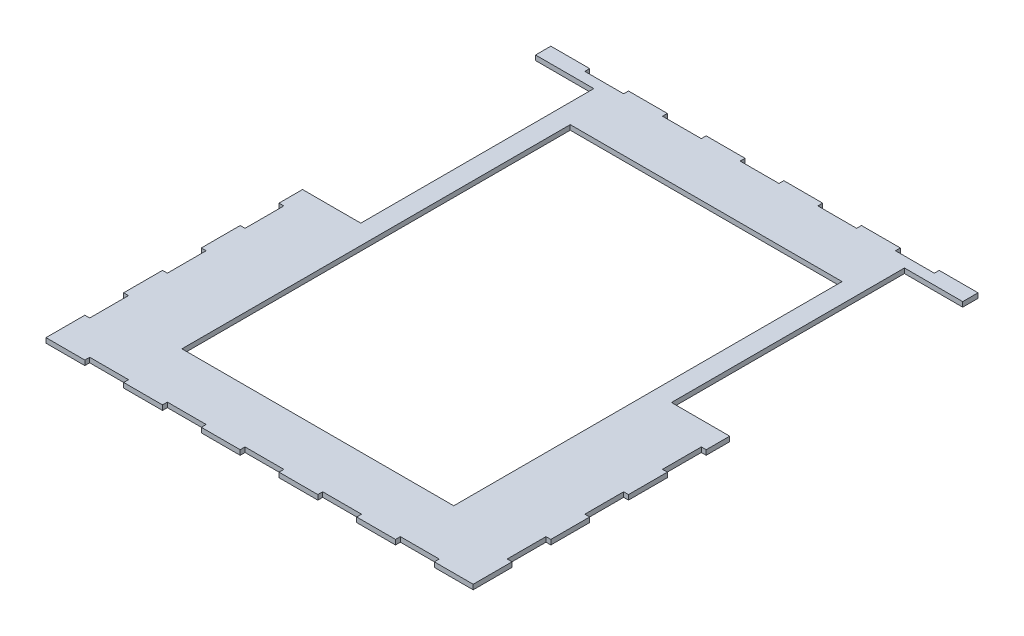
from build123d import *

# Parameters (mm, degrees)
BOSS_EXTRUDE1_DEPTH     = 3.175
SKETCH4_W               = 38.1
SKETCH4_H               = 152.4
CUT_EXTRUDE2_DEPTH      = 1
CUT_EXTRUDE2_DEPTH_BACK = 4.175
SKETCH2_W               = 177.8
SKETCH2_H               = 254
CUT_EXTRUDE1_DEPTH      = 1
CUT_EXTRUDE1_DEPTH_BACK = 4.175


with BuildPart() as part:
    # Sketch1 → Boss-Extrude1 (new body)
    with BuildSketch(Plane(origin=(0, 0, 0), x_dir=(1, 0, 0), z_dir=(0, 1, 0))):
        Polygon((-139.7, 0), (0, 0), (0, 161.925), (-12.7, 161.925), (-12.7, 165.1), (-38.1, 165.1), (-38.1, 161.925), (-63.5, 161.925), (-63.5, 165.1), (-88.9, 165.1), (-88.9, 161.925), (-114.3, 161.925), (-114.3, 165.1), (-139.7, 165.1), (-139.7, 139.7), (-136.525, 139.7), (-136.525, 114.3), (-139.7, 114.3), (-139.7, 88.9), (-136.525, 88.9), (-136.525, 63.5), (-139.7, 63.5), (-139.7, 38.1), (-136.525, 38.1), (-136.525, 12.7), (-139.7, 12.7), align=None)
    extrude(amount=BOSS_EXTRUDE1_DEPTH)

    # Mirror1: part across plane


with BuildPart() as part_1:
    add(part.part)
    add(part.part.mirror(Plane(origin=(-139.7, 3.175, 0), x_dir=(1, 0, 0), z_dir=(0, 0, -1))))

    # Sketch4 → Cut-Extrude2 (cut, two sides)
    with BuildSketch(Plane(origin=(0, 3.175, 0), x_dir=(1, 0, 0), z_dir=(0, 1, 0))) as cut_extrude2_sk:
        with Locations((-120.65, 78.9)):
            Rectangle(SKETCH4_W, SKETCH4_H)
    extrude(amount=CUT_EXTRUDE2_DEPTH, mode=Mode.SUBTRACT)
    extrude(cut_extrude2_sk.sketch, amount=-CUT_EXTRUDE2_DEPTH_BACK, mode=Mode.SUBTRACT)

    # Mirror2: part across plane


with BuildPart() as part_2:
    add(part_1.part)
    add(part_1.part.mirror(Plane(origin=(0, 3.175, 0), x_dir=(0, 0, 1), z_dir=(-1, 0, 0))))

    # Sketch2 → Cut-Extrude1 (cut, two sides)
    with BuildSketch(Plane(origin=(0, 3.175, 0), x_dir=(1, 0, 0), z_dir=(0, 1, 0))) as cut_extrude1_sk:
        Rectangle(SKETCH2_W, SKETCH2_H)
    extrude(amount=CUT_EXTRUDE1_DEPTH, mode=Mode.SUBTRACT)
    extrude(cut_extrude1_sk.sketch, amount=-CUT_EXTRUDE1_DEPTH_BACK, mode=Mode.SUBTRACT)


solid = part_2.part
